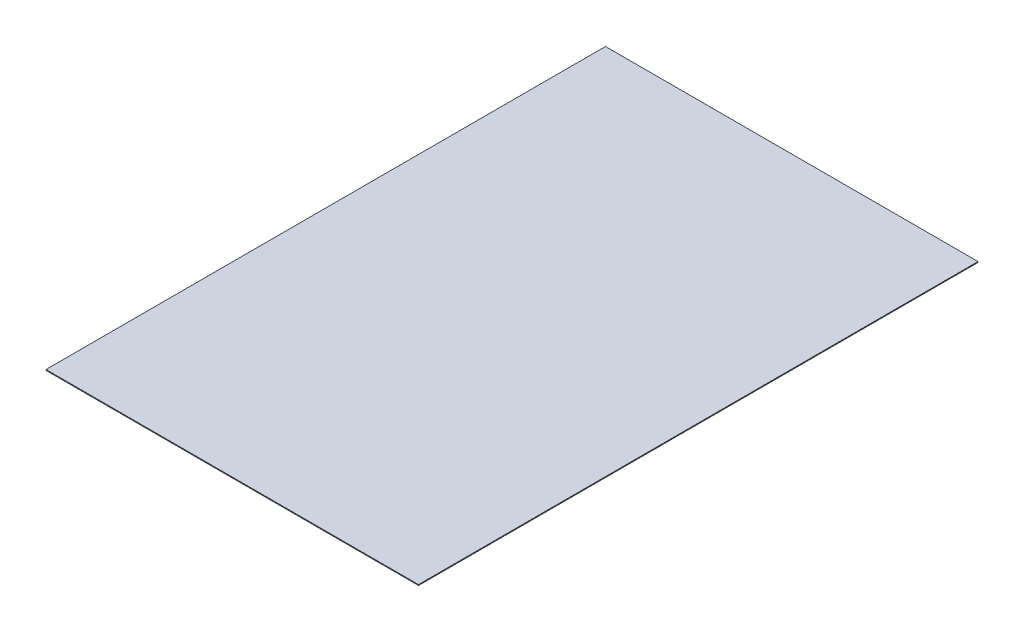
from build123d import *

# Parameters (mm, degrees)
SKETCH1_W           = 6725
SKETCH1_H           = 10100
BOSS_EXTRUDE1_DEPTH = 15


with BuildPart() as part:
    # Sketch1 → Boss-Extrude1 (new body)
    with BuildSketch(Plane(origin=(0, 0, 0), x_dir=(1, 0, 0), z_dir=(0, 1, 0))):
        with Locations((-3362.5, 0)):
            Rectangle(SKETCH1_W, SKETCH1_H)
    extrude(amount=-BOSS_EXTRUDE1_DEPTH)


solid = part.part
